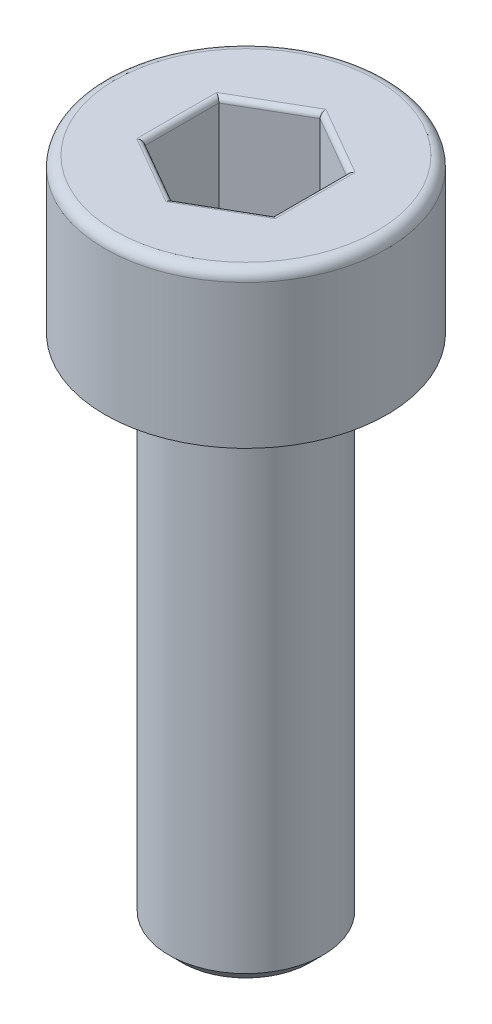
from build123d import *

# Parameters (mm, degrees)
CHAMFER1_SIZE      = 0.25
FILLET1_R          = 0.2
CUT_EXTRUDE1_DEPTH = 2
FILLET2_R          = 0.1


with BuildPart() as part:
    # Sketch1 → Revolve1 (revolve)
    with BuildSketch(Plane.XY):
        Polygon((0, -13), (-1.5, -13), (-1.5, -3), (-2.75, -3), (-2.75, 0), (0, 0), align=None)
    revolve(axis=Axis((0, 0, 0), (0, -1, 0)))

    # Chamfer1
    chamfer1_edges = [part.edges().sort_by_distance(p)[0] for p in [
        (1.5, -3, 0),
        (1.5, -13, 0),
    ]]
    chamfer(chamfer1_edges, length=CHAMFER1_SIZE)

    # Fillet1
    fillet1_edges = [part.edges().sort_by_distance(p)[0] for p in [
        (2.75, 0, 0),
    ]]
    fillet(fillet1_edges, radius=FILLET1_R)

    # Sketch2 → Cut-Extrude1 (cut)
    with BuildSketch(Plane(origin=(0, 0, 0), x_dir=(1, 0, 0), z_dir=(0, 1, 0))):
        Polygon((0, 1.443375673), (-1.25, 0.721687836), (-1.25, -0.721687836), (0, -1.443375673), (1.25, -0.721687836), (1.25, 0.721687836), align=None)
    extrude(amount=-CUT_EXTRUDE1_DEPTH, mode=Mode.SUBTRACT)

    # Fillet2
    fillet2_edges = [part.edges().sort_by_distance(p)[0] for p in [
        (0.625, -2, -1.082531755),
        (1.25, -2, 0),
        (0.625, -2, 1.082531755),
        (-0.625, -2, 1.082531755),
        (-1.25, -2, 0),
        (-0.625, -2, -1.082531755),
        (0.625, 0, -1.082531755),
        (-0.625, 0, -1.082531755),
        (-1.25, 0, 0),
        (-0.625, 0, 1.082531755),
        (0.625, 0, 1.082531755),
        (1.25, 0, 0),
    ]]
    fillet(fillet2_edges, radius=FILLET2_R)


solid = part.part
